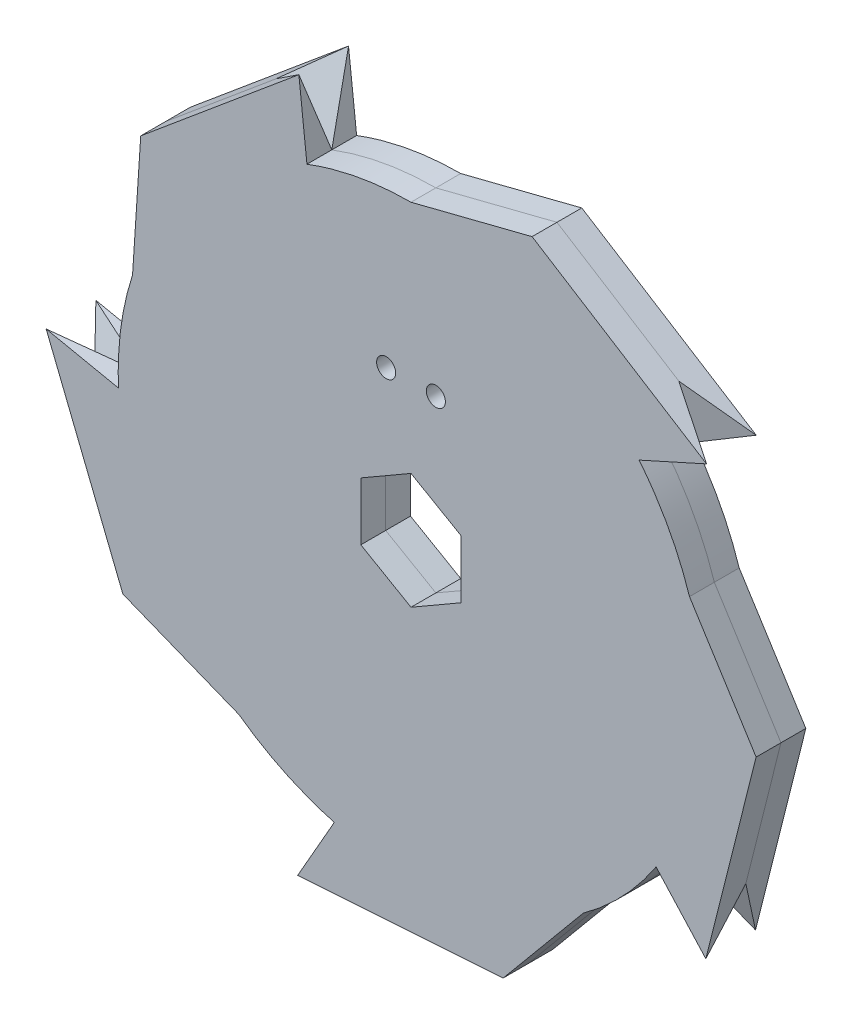
from build123d import *

# Parameters (mm, degrees)
BOSS_EXTRUDE1_DEPTH             = 6.35
SCALE1_SCALE_X                  = 1.886597937
SCALE1_SCALE_Y                  = 1.88659794
SCALE1_SCALE_Z                  = 1
CUT_EXTRUDE2_DEPTH              = 7.3500001
F_41_0_096_DIAMETER_HOLE1_D     = 2.4384
F_41_0_096_DIAMETER_HOLE1_DEPTH = 6.35
CIRPATTERN1_COUNT               = 5


with BuildPart() as part:
    # Sketch1 → Boss-Extrude1 (new body)
    with BuildSketch(Plane.XY):
        with BuildLine():
            Line((0, 19.834855), (8.201335358, 21.916452907))
            Line((8.201335358, 21.916452907), (20.01835, 14.492581538))
            Line((20.01835, 14.492581538), (15.453846792, 12.433828541))
            ThreePointArc((15.453846792, 12.433828541), (17.446104657, 9.436890652), (18.864068098, 6.129307276))
            Line((18.864068098, 6.129307276), (23.378137353, -1.02737703))
            Line((23.378137353, -1.02737703), (19.969274459, -14.560128225))
            Line((19.969274459, -14.560128225), (16.600774944, -10.855217369))
            ThreePointArc((16.600774944, -10.855217369), (14.366159173, -13.676071932), (11.65863525, -16.046734776))
            Line((11.65863525, -16.046734776), (6.24714812, -22.551406831))
            Line((6.24714812, -22.551406831), (-7.676659654, -23.491235662))
            Line((-7.676659654, -23.491235662), (-5.194003637, -19.142721831))
            ThreePointArc((-5.194003637, -19.142721831), (-8.56733, -17.889167939), (-11.65863525, -16.046734776))
            Line((-11.65863525, -16.046734776), (-19.517187483, -12.910158885))
            Line((-19.517187483, -12.910158885), (-24.713711045, 0.041746149))
            Line((-24.713711045, 0.041746149), (-19.810845729, -0.97563536))
            ThreePointArc((-19.810845729, -0.97563536), (-19.661060306, 2.619958115), (-18.864068098, 6.129307276))
            Line((-18.864068098, 6.129307276), (-18.309433349, 14.572489839))
            Line((-18.309433349, 14.572489839), (-7.59725376, 23.517036201))
            Line((-7.59725376, 23.517036201), (-7.04977237, 18.539746018))
            ThreePointArc((-7.04977237, 18.539746018), (-3.583873524, 19.508391103), (0, 19.834855))
        make_face()
    extrude(amount=BOSS_EXTRUDE1_DEPTH)


with BuildPart() as part_1:
    # Scale1: scaled about (0, 0, 0)
    add(part.part.scale((SCALE1_SCALE_X, SCALE1_SCALE_Y, SCALE1_SCALE_Z), about=(0, 0, 0)))

    # Sketch3 → Cut-Extrude2 (cut, through all)
    with BuildSketch(Plane.XY.offset(6.35)):
        Polygon((6.4135, 3.702835951), (0, 7.405671903), (-6.4135, 3.702835951), (-6.4135, -3.702835951), (0, -7.405671903), (6.4135, -3.702835951), align=None)
    extrude(amount=-CUT_EXTRUDE2_DEPTH, mode=Mode.SUBTRACT)

    # 41 _0.096_ Diameter Hole1
    with Locations(Plane.XY.offset(6.35)):
        with Locations((-3.175, 17.526), (3.175, 17.526)):
            Hole(F_41_0_096_DIAMETER_HOLE1_D / 2, depth=F_41_0_096_DIAMETER_HOLE1_DEPTH)

    # Sketch7 → Cut-Loft1 section 0
    with BuildSketch(Plane(origin=(2.912159258, -43.144394285, 0), x_dir=(0.997729766, 0.067344739, 0), z_dir=(0.067344739, -0.997729766, 0)), mode=Mode.PRIVATE) as cut_loft1_s0:
        Polygon((-17.434509943, 6.35), (-9.497009943, 3.175), (-17.434509943, 0), align=None)
    cut_loft1 = loft([Vertex(-9.798996549, -36.114619572, 3.175), cut_loft1_s0.sketch], mode=Mode.SUBTRACT)

    # CirPattern1: Cut-Loft1 ×5 about axis
    cirpattern1_axis = Axis((0, 0, 0), (0, 0, 1))
    for i in range(1, CIRPATTERN1_COUNT):
        add(cut_loft1.rotate(cirpattern1_axis, i * 360 / CIRPATTERN1_COUNT), mode=Mode.SUBTRACT)


with BuildPart() as body_2:
    # Split1: the piece on the far side of the plane
    add(part_1.part)
    split(bisect_by=Plane.XY.offset(3.175), keep=Keep.BOTTOM)


with BuildPart() as part_2:
    add(part_1.part)

    # Split1
    split(bisect_by=Plane.XY.offset(3.175), keep=Keep.TOP)


solid = Compound([body_2.part, part_2.part])
